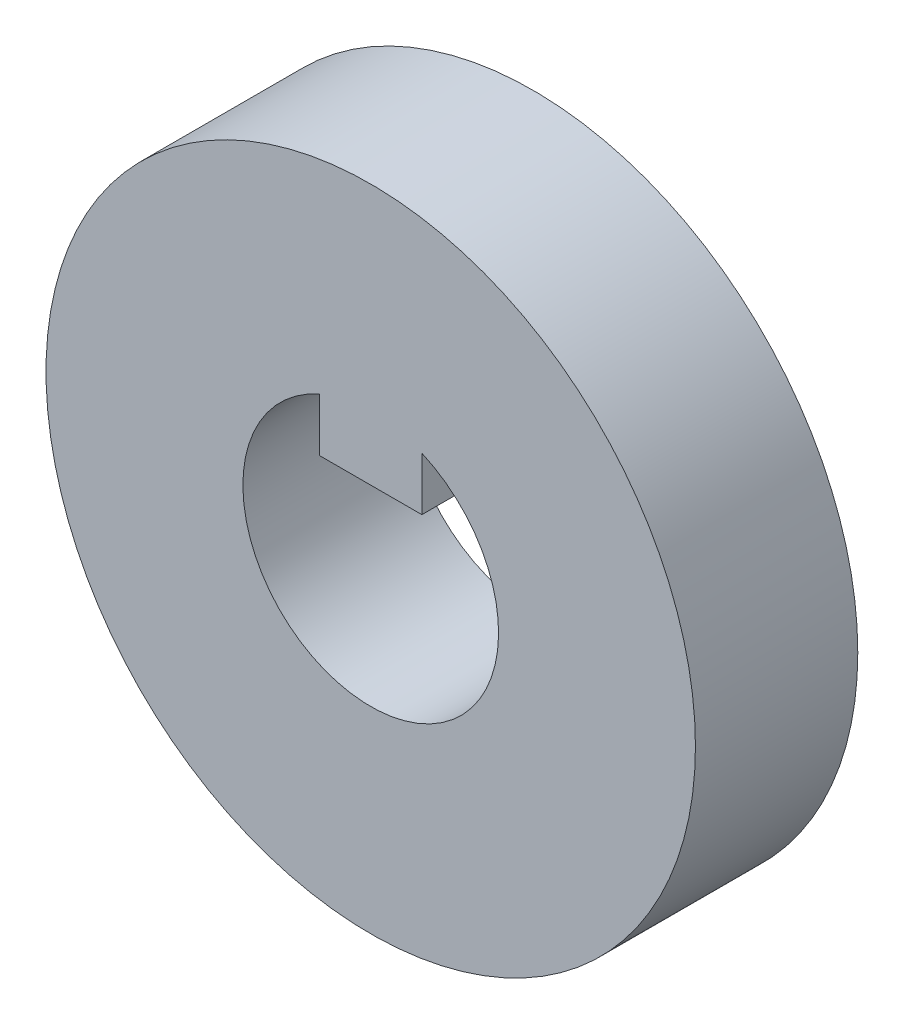
from build123d import *

# Parameters (mm, degrees)
SKETCH1_R           = 25.4
BOSS_EXTRUDE1_DEPTH = 12.7


with BuildPart() as part:
    # Sketch1 → Boss-Extrude1 (new body)
    with BuildSketch(Plane.XY):
        Circle(SKETCH1_R)
        with BuildLine():
            Line((-4, 9.16515139), (-4, 5))
            Line((-4, 5), (4, 5))
            Line((4, 5), (4, 9.16515139))
            ThreePointArc((4, 9.16515139), (0, -10), (-4, 9.16515139))
        make_face(mode=Mode.SUBTRACT)
    extrude(amount=BOSS_EXTRUDE1_DEPTH)


solid = part.part
